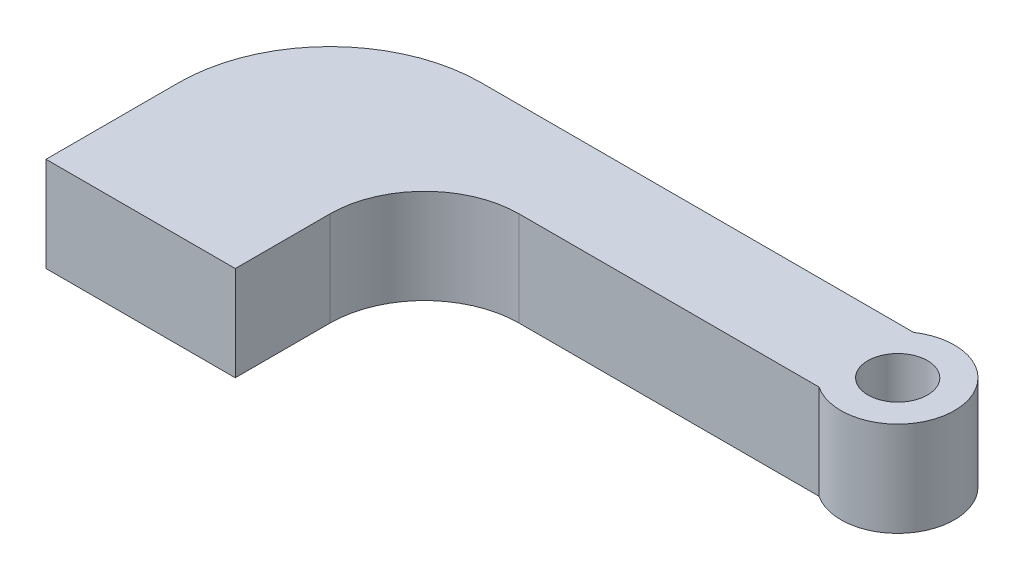
from build123d import *

# Parameters (mm, degrees)
SKETCH1_R           = 2
BOSS_EXTRUDE1_DEPTH = 6.35


with BuildPart() as part:
    # Sketch1 → Boss-Extrude1 (new body)
    with BuildSketch(Plane(origin=(0, 0, 0), x_dir=(1, 0, 0), z_dir=(0, 1, 0))):
        with BuildLine():
            Line((12.7, 0), (12.7, 6.35))
            ThreePointArc((12.7, 6.35), (14.559871939, 10.840128061), (19.05, 12.7))
            Line((19.05, 12.7), (39.168815004, 12.7))
            ThreePointArc((39.168815004, 12.7), (45.084999997, 15.87476101), (39.169071524, 19.05))
            Line((39.169071524, 19.05), (12.7, 19.05))
            Line((12.7, 19.05), (10.16, 19.05))
            ThreePointArc((10.16, 19.05), (2.975795103, 16.074204897), (0, 8.89))
            Line((0, 8.89), (0, 0))
            Line((0, 0), (12.7, 0))
        make_face()
        with Locations((41.275, 15.874914922)):
            Circle(SKETCH1_R, mode=Mode.SUBTRACT)
    extrude(amount=BOSS_EXTRUDE1_DEPTH)


solid = part.part
